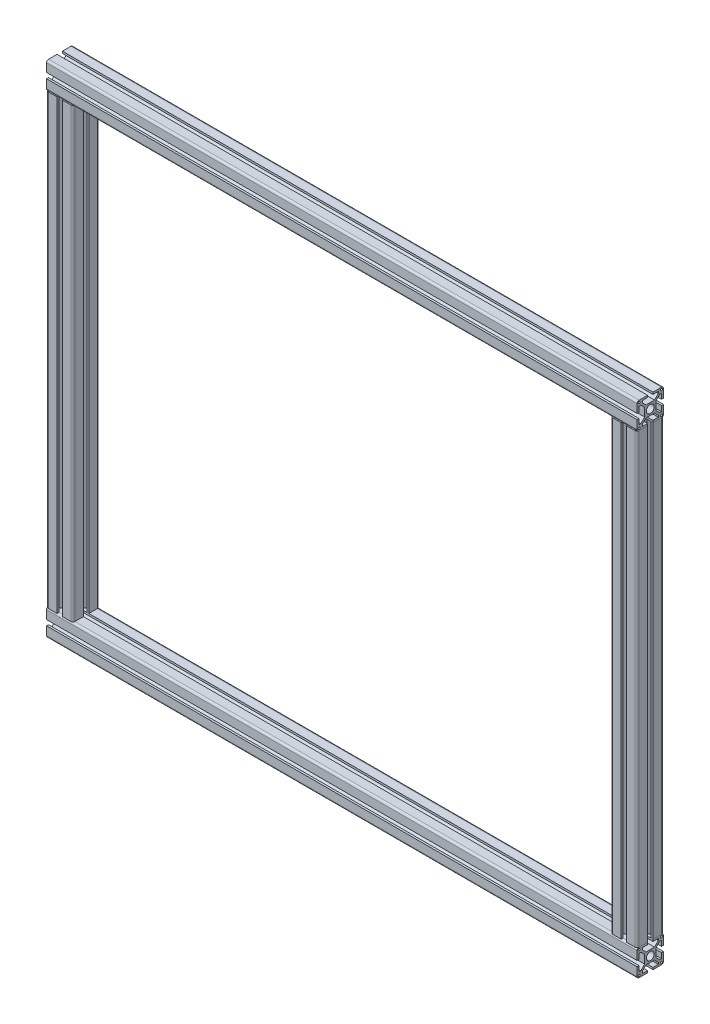
from build123d import *

# Parameters (mm, degrees)
SKETCH1_R                     = 6
SKETCH1_R_2                   = 1.5
F_4040_4040_ALEX_1_DEPTH      = 875
F_4040_4040_ALEX_1_DEPTH_BACK = 20
SKETCH1_ON_SEGMENT_2_R        = 6
SKETCH1_ON_SEGMENT_2_R_2      = 1.5
F_4040_4040_ALEX_1_2_DEPTH    = 895
SKETCH1_ON_SEGMENT_3_R        = 6
SKETCH1_ON_SEGMENT_3_R_2      = 1.5
F_4040_4040_ALEX_1_3_DEPTH    = 720
SKETCH1_ON_SEGMENT_4_R        = 6
SKETCH1_ON_SEGMENT_4_R_2      = 1.5
F_4040_4040_ALEX_1_4_DEPTH    = 720


with BuildPart() as part:
    # Sketch1 → 4040 4040_ALEX(1) (new, two sides)
    with BuildSketch(Plane(origin=(855, 718, 0), x_dir=(0, 0, 1), z_dir=(-1, 0, 0))) as f_4040_4040_alex_1_sk:
        with BuildLine():
            Line((6.378679656, 8.5), (-6.378679656, 8.5))
            Line((-6.378679656, 8.5), (-12.128679656, 14.25))
            Line((-12.128679656, 14.25), (-12.128679656, 17))
            Line((-12.128679656, 17), (-4.1, 17))
            Line((-4.1, 17), (-4.1, 20))
            Line((-4.1, 20), (-17, 20))
            ThreePointArc((-17, 20), (-19.121320344, 19.121320344), (-20, 17))
            Line((-20, 17), (-20, 4.1))
            Line((-20, 4.1), (-17, 4.1))
            Line((-17, 4.1), (-17, 12.128679656))
            Line((-17, 12.128679656), (-14.25, 12.128679656))
            Line((-14.25, 12.128679656), (-8.5, 6.378679656))
            Line((-8.5, 6.378679656), (-8.5, -6.378679656))
            Line((-8.5, -6.378679656), (-14.25, -12.128679656))
            Line((-14.25, -12.128679656), (-17, -12.128679656))
            Line((-17, -12.128679656), (-17, -4.1))
            Line((-17, -4.1), (-20, -4.1))
            Line((-20, -4.1), (-20, -17))
            ThreePointArc((-20, -17), (-19.121320344, -19.121320344), (-17, -20))
            Line((-17, -20), (-4.1, -20))
            Line((-4.1, -20), (-4.1, -17))
            Line((-4.1, -17), (-12.128679656, -17))
            Line((-12.128679656, -17), (-12.128679656, -14.25))
            Line((-12.128679656, -14.25), (-6.378679656, -8.5))
            Line((-6.378679656, -8.5), (6.378679656, -8.5))
            Line((6.378679656, -8.5), (12.128679656, -14.25))
            Line((12.128679656, -14.25), (12.128679656, -17))
            Line((12.128679656, -17), (4.1, -17))
            Line((4.1, -17), (4.1, -20))
            Line((4.1, -20), (17, -20))
            ThreePointArc((17, -20), (19.121320344, -19.121320344), (20, -17))
            Line((20, -17), (20, -4.1))
            Line((20, -4.1), (17, -4.1))
            Line((17, -4.1), (17, -12.128679656))
            Line((17, -12.128679656), (14.25, -12.128679656))
            Line((14.25, -12.128679656), (8.5, -6.378679656))
            Line((8.5, -6.378679656), (8.5, 6.378679656))
            Line((8.5, 6.378679656), (14.25, 12.128679656))
            Line((14.25, 12.128679656), (17, 12.128679656))
            Line((17, 12.128679656), (17, 4.1))
            Line((17, 4.1), (20, 4.1))
            Line((20, 4.1), (20, 17))
            ThreePointArc((20, 17), (19.121320344, 19.121320344), (17, 20))
            Line((17, 20), (4.1, 20))
            Line((4.1, 20), (4.1, 17))
            Line((4.1, 17), (12.128679656, 17))
            Line((12.128679656, 17), (12.128679656, 14.25))
            Line((12.128679656, 14.25), (6.378679656, 8.5))
        make_face()
        Circle(SKETCH1_R, mode=Mode.SUBTRACT)
        with Locations((-17, 17)):
            Circle(SKETCH1_R_2, mode=Mode.SUBTRACT)
        with Locations((17, 17)):
            Circle(SKETCH1_R_2, mode=Mode.SUBTRACT)
        with Locations((17, -17)):
            Circle(SKETCH1_R_2, mode=Mode.SUBTRACT)
        with Locations((-17, -17)):
            Circle(SKETCH1_R_2, mode=Mode.SUBTRACT)
    extrude(amount=F_4040_4040_ALEX_1_DEPTH)
    extrude(f_4040_4040_alex_1_sk.sketch, amount=-F_4040_4040_ALEX_1_DEPTH_BACK)


with BuildPart() as body_2:
    # Sketch1 on segment 2 (carried to segment 2) → 4040 4040_ALEX_1 2 (new body)
    with BuildSketch(Plane.ZY.offset(-875)):
        with BuildLine():
            Line((6.378679656, 8.5), (-6.378679656, 8.5))
            Line((-6.378679656, 8.5), (-12.128679656, 14.25))
            Line((-12.128679656, 14.25), (-12.128679656, 17))
            Line((-12.128679656, 17), (-4.1, 17))
            Line((-4.1, 17), (-4.1, 20))
            Line((-4.1, 20), (-17, 20))
            ThreePointArc((-17, 20), (-19.121320344, 19.121320344), (-20, 17))
            Line((-20, 17), (-20, 4.1))
            Line((-20, 4.1), (-17, 4.1))
            Line((-17, 4.1), (-17, 12.128679656))
            Line((-17, 12.128679656), (-14.25, 12.128679656))
            Line((-14.25, 12.128679656), (-8.5, 6.378679656))
            Line((-8.5, 6.378679656), (-8.5, -6.378679656))
            Line((-8.5, -6.378679656), (-14.25, -12.128679656))
            Line((-14.25, -12.128679656), (-17, -12.128679656))
            Line((-17, -12.128679656), (-17, -4.1))
            Line((-17, -4.1), (-20, -4.1))
            Line((-20, -4.1), (-20, -17))
            ThreePointArc((-20, -17), (-19.121320344, -19.121320344), (-17, -20))
            Line((-17, -20), (-4.1, -20))
            Line((-4.1, -20), (-4.1, -17))
            Line((-4.1, -17), (-12.128679656, -17))
            Line((-12.128679656, -17), (-12.128679656, -14.25))
            Line((-12.128679656, -14.25), (-6.378679656, -8.5))
            Line((-6.378679656, -8.5), (6.378679656, -8.5))
            Line((6.378679656, -8.5), (12.128679656, -14.25))
            Line((12.128679656, -14.25), (12.128679656, -17))
            Line((12.128679656, -17), (4.1, -17))
            Line((4.1, -17), (4.1, -20))
            Line((4.1, -20), (17, -20))
            ThreePointArc((17, -20), (19.121320344, -19.121320344), (20, -17))
            Line((20, -17), (20, -4.1))
            Line((20, -4.1), (17, -4.1))
            Line((17, -4.1), (17, -12.128679656))
            Line((17, -12.128679656), (14.25, -12.128679656))
            Line((14.25, -12.128679656), (8.5, -6.378679656))
            Line((8.5, -6.378679656), (8.5, 6.378679656))
            Line((8.5, 6.378679656), (14.25, 12.128679656))
            Line((14.25, 12.128679656), (17, 12.128679656))
            Line((17, 12.128679656), (17, 4.1))
            Line((17, 4.1), (20, 4.1))
            Line((20, 4.1), (20, 17))
            ThreePointArc((20, 17), (19.121320344, 19.121320344), (17, 20))
            Line((17, 20), (4.1, 20))
            Line((4.1, 20), (4.1, 17))
            Line((4.1, 17), (12.128679656, 17))
            Line((12.128679656, 17), (12.128679656, 14.25))
            Line((12.128679656, 14.25), (6.378679656, 8.5))
        make_face()
        Circle(SKETCH1_ON_SEGMENT_2_R, mode=Mode.SUBTRACT)
        with Locations((-17, 17)):
            Circle(SKETCH1_ON_SEGMENT_2_R_2, mode=Mode.SUBTRACT)
        with Locations((17, 17)):
            Circle(SKETCH1_ON_SEGMENT_2_R_2, mode=Mode.SUBTRACT)
        with Locations((17, -17)):
            Circle(SKETCH1_ON_SEGMENT_2_R_2, mode=Mode.SUBTRACT)
        with Locations((-17, -17)):
            Circle(SKETCH1_ON_SEGMENT_2_R_2, mode=Mode.SUBTRACT)
    extrude(amount=F_4040_4040_ALEX_1_2_DEPTH)


with BuildPart() as body_3:
    # Sketch1 on segment 3 (carried to segment 3) → 4040 4040_ALEX_1 3 (new body)
    with BuildSketch(Plane(origin=(0, 719, 0), x_dir=(0, 0, 1), z_dir=(0, -1, 0))):
        with BuildLine():
            Line((6.378679656, 8.5), (-6.378679656, 8.5))
            Line((-6.378679656, 8.5), (-12.128679656, 14.25))
            Line((-12.128679656, 14.25), (-12.128679656, 17))
            Line((-12.128679656, 17), (-4.1, 17))
            Line((-4.1, 17), (-4.1, 20))
            Line((-4.1, 20), (-17, 20))
            ThreePointArc((-17, 20), (-19.121320344, 19.121320344), (-20, 17))
            Line((-20, 17), (-20, 4.1))
            Line((-20, 4.1), (-17, 4.1))
            Line((-17, 4.1), (-17, 12.128679656))
            Line((-17, 12.128679656), (-14.25, 12.128679656))
            Line((-14.25, 12.128679656), (-8.5, 6.378679656))
            Line((-8.5, 6.378679656), (-8.5, -6.378679656))
            Line((-8.5, -6.378679656), (-14.25, -12.128679656))
            Line((-14.25, -12.128679656), (-17, -12.128679656))
            Line((-17, -12.128679656), (-17, -4.1))
            Line((-17, -4.1), (-20, -4.1))
            Line((-20, -4.1), (-20, -17))
            ThreePointArc((-20, -17), (-19.121320344, -19.121320344), (-17, -20))
            Line((-17, -20), (-4.1, -20))
            Line((-4.1, -20), (-4.1, -17))
            Line((-4.1, -17), (-12.128679656, -17))
            Line((-12.128679656, -17), (-12.128679656, -14.25))
            Line((-12.128679656, -14.25), (-6.378679656, -8.5))
            Line((-6.378679656, -8.5), (6.378679656, -8.5))
            Line((6.378679656, -8.5), (12.128679656, -14.25))
            Line((12.128679656, -14.25), (12.128679656, -17))
            Line((12.128679656, -17), (4.1, -17))
            Line((4.1, -17), (4.1, -20))
            Line((4.1, -20), (17, -20))
            ThreePointArc((17, -20), (19.121320344, -19.121320344), (20, -17))
            Line((20, -17), (20, -4.1))
            Line((20, -4.1), (17, -4.1))
            Line((17, -4.1), (17, -12.128679656))
            Line((17, -12.128679656), (14.25, -12.128679656))
            Line((14.25, -12.128679656), (8.5, -6.378679656))
            Line((8.5, -6.378679656), (8.5, 6.378679656))
            Line((8.5, 6.378679656), (14.25, 12.128679656))
            Line((14.25, 12.128679656), (17, 12.128679656))
            Line((17, 12.128679656), (17, 4.1))
            Line((17, 4.1), (20, 4.1))
            Line((20, 4.1), (20, 17))
            ThreePointArc((20, 17), (19.121320344, 19.121320344), (17, 20))
            Line((17, 20), (4.1, 20))
            Line((4.1, 20), (4.1, 17))
            Line((4.1, 17), (12.128679656, 17))
            Line((12.128679656, 17), (12.128679656, 14.25))
            Line((12.128679656, 14.25), (6.378679656, 8.5))
        make_face()
        Circle(SKETCH1_ON_SEGMENT_3_R, mode=Mode.SUBTRACT)
        with Locations((-17, 17)):
            Circle(SKETCH1_ON_SEGMENT_3_R_2, mode=Mode.SUBTRACT)
        with Locations((17, 17)):
            Circle(SKETCH1_ON_SEGMENT_3_R_2, mode=Mode.SUBTRACT)
        with Locations((17, -17)):
            Circle(SKETCH1_ON_SEGMENT_3_R_2, mode=Mode.SUBTRACT)
        with Locations((-17, -17)):
            Circle(SKETCH1_ON_SEGMENT_3_R_2, mode=Mode.SUBTRACT)
    extrude(amount=F_4040_4040_ALEX_1_3_DEPTH)

    # 4040 4040_ALEX_1 3 end butt 1
    split(bisect_by=Plane.XZ.offset(-698), keep=Keep.TOP)

    # 4040 4040_ALEX_1 3 end butt 2
    split(bisect_by=Plane(origin=(0, 20, 0), x_dir=(-1, 0, 0), z_dir=(0, 1, 0)), keep=Keep.TOP)


with BuildPart() as body_4:
    # Sketch1 on segment 4 (carried to segment 4) → 4040 4040_ALEX_1 4 (new body)
    with BuildSketch(Plane(origin=(855, -1, 0), x_dir=(0, 0, 1), z_dir=(0, 1, 0))):
        with BuildLine():
            Line((6.378679656, 8.5), (-6.378679656, 8.5))
            Line((-6.378679656, 8.5), (-12.128679656, 14.25))
            Line((-12.128679656, 14.25), (-12.128679656, 17))
            Line((-12.128679656, 17), (-4.1, 17))
            Line((-4.1, 17), (-4.1, 20))
            Line((-4.1, 20), (-17, 20))
            ThreePointArc((-17, 20), (-19.121320344, 19.121320344), (-20, 17))
            Line((-20, 17), (-20, 4.1))
            Line((-20, 4.1), (-17, 4.1))
            Line((-17, 4.1), (-17, 12.128679656))
            Line((-17, 12.128679656), (-14.25, 12.128679656))
            Line((-14.25, 12.128679656), (-8.5, 6.378679656))
            Line((-8.5, 6.378679656), (-8.5, -6.378679656))
            Line((-8.5, -6.378679656), (-14.25, -12.128679656))
            Line((-14.25, -12.128679656), (-17, -12.128679656))
            Line((-17, -12.128679656), (-17, -4.1))
            Line((-17, -4.1), (-20, -4.1))
            Line((-20, -4.1), (-20, -17))
            ThreePointArc((-20, -17), (-19.121320344, -19.121320344), (-17, -20))
            Line((-17, -20), (-4.1, -20))
            Line((-4.1, -20), (-4.1, -17))
            Line((-4.1, -17), (-12.128679656, -17))
            Line((-12.128679656, -17), (-12.128679656, -14.25))
            Line((-12.128679656, -14.25), (-6.378679656, -8.5))
            Line((-6.378679656, -8.5), (6.378679656, -8.5))
            Line((6.378679656, -8.5), (12.128679656, -14.25))
            Line((12.128679656, -14.25), (12.128679656, -17))
            Line((12.128679656, -17), (4.1, -17))
            Line((4.1, -17), (4.1, -20))
            Line((4.1, -20), (17, -20))
            ThreePointArc((17, -20), (19.121320344, -19.121320344), (20, -17))
            Line((20, -17), (20, -4.1))
            Line((20, -4.1), (17, -4.1))
            Line((17, -4.1), (17, -12.128679656))
            Line((17, -12.128679656), (14.25, -12.128679656))
            Line((14.25, -12.128679656), (8.5, -6.378679656))
            Line((8.5, -6.378679656), (8.5, 6.378679656))
            Line((8.5, 6.378679656), (14.25, 12.128679656))
            Line((14.25, 12.128679656), (17, 12.128679656))
            Line((17, 12.128679656), (17, 4.1))
            Line((17, 4.1), (20, 4.1))
            Line((20, 4.1), (20, 17))
            ThreePointArc((20, 17), (19.121320344, 19.121320344), (17, 20))
            Line((17, 20), (4.1, 20))
            Line((4.1, 20), (4.1, 17))
            Line((4.1, 17), (12.128679656, 17))
            Line((12.128679656, 17), (12.128679656, 14.25))
            Line((12.128679656, 14.25), (6.378679656, 8.5))
        make_face()
        Circle(SKETCH1_ON_SEGMENT_4_R, mode=Mode.SUBTRACT)
        with Locations((-17, 17)):
            Circle(SKETCH1_ON_SEGMENT_4_R_2, mode=Mode.SUBTRACT)
        with Locations((17, 17)):
            Circle(SKETCH1_ON_SEGMENT_4_R_2, mode=Mode.SUBTRACT)
        with Locations((17, -17)):
            Circle(SKETCH1_ON_SEGMENT_4_R_2, mode=Mode.SUBTRACT)
        with Locations((-17, -17)):
            Circle(SKETCH1_ON_SEGMENT_4_R_2, mode=Mode.SUBTRACT)
    extrude(amount=F_4040_4040_ALEX_1_4_DEPTH)

    # 4040 4040_ALEX_1 4 end butt 1
    split(bisect_by=Plane(origin=(855, 20, 0), x_dir=(-1, 0, 0), z_dir=(0, 1, 0)), keep=Keep.TOP)

    # 4040 4040_ALEX_1 4 end butt 2
    split(bisect_by=Plane(origin=(855, 698, 0), x_dir=(1, 0, 0), z_dir=(0, -1, 0)), keep=Keep.TOP)


solid = Compound([part.part, body_2.part, body_3.part, body_4.part])
